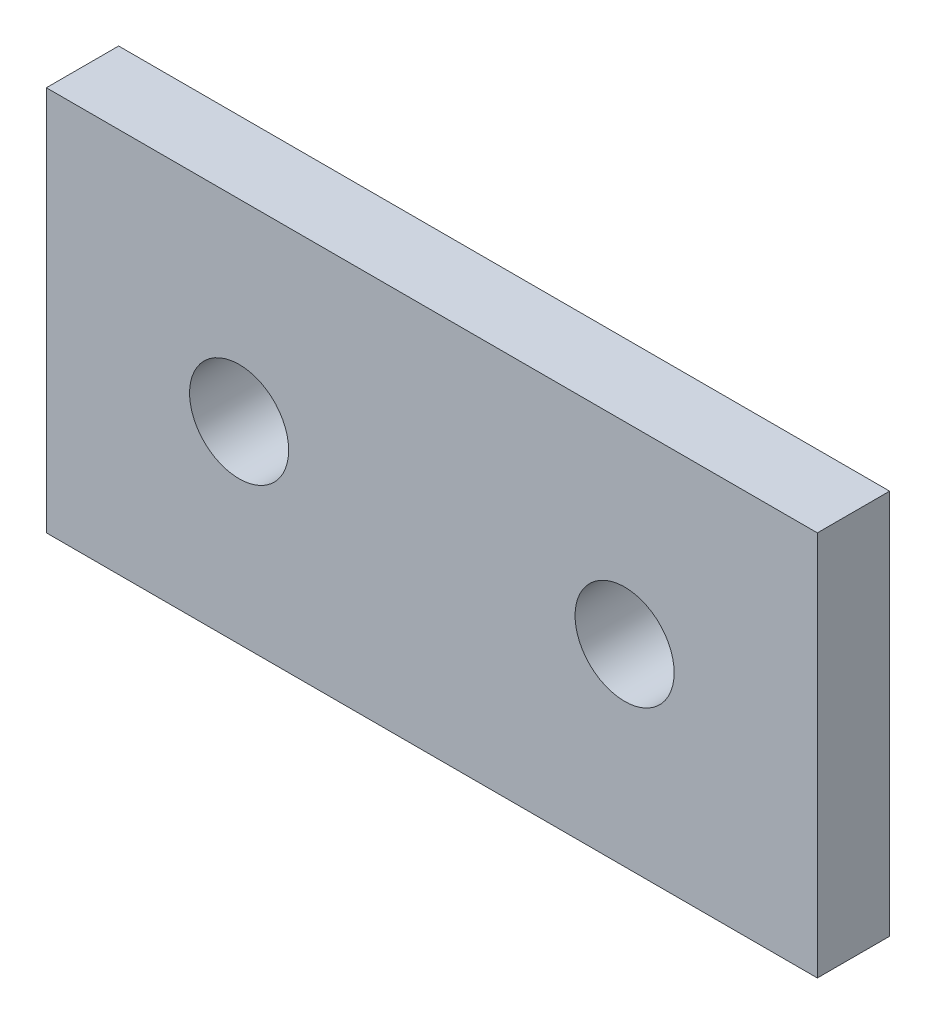
from build123d import *

# Parameters (mm, degrees)
SKETCH1_W           = 50.8
SKETCH1_H           = 25.4
SKETCH1_R           = 3.2639
BOSS_EXTRUDE1_DEPTH = 2.38125


with BuildPart() as part:
    # Sketch1 → Boss-Extrude1 (new body, symmetric)
    with BuildSketch(Plane.XY):
        with Locations((25.4, 12.7)):
            Rectangle(SKETCH1_W, SKETCH1_H)
        with Locations((12.7, 12.7)):
            Circle(SKETCH1_R, mode=Mode.SUBTRACT)
        with Locations((38.1, 12.7)):
            Circle(SKETCH1_R, mode=Mode.SUBTRACT)
    extrude(amount=BOSS_EXTRUDE1_DEPTH, both=True)


solid = part.part
